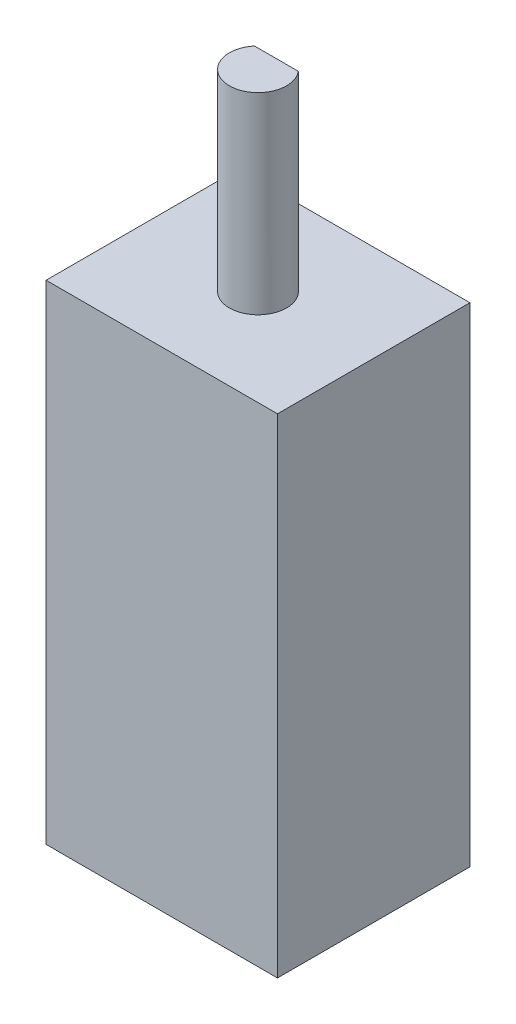
from build123d import *

# Parameters (mm, degrees)
SKETCH1_W           = 12.065
SKETCH1_H           = 25.4762
BOSS_EXTRUDE1_DEPTH = 10.033
SKETCH2_R           = 1.49225
BOSS_EXTRUDE2_DEPTH = 10.033
CUT_EXTRUDE1_DEPTH  = 8.6106


with BuildPart() as part:
    # Sketch1 → Boss-Extrude1 (new body)
    with BuildSketch(Plane.XY):
        with Locations((6.0325, 12.7381)):
            Rectangle(SKETCH1_W, SKETCH1_H)
    extrude(amount=BOSS_EXTRUDE1_DEPTH)

    # Sketch2 → Boss-Extrude2 (add)
    with BuildSketch(Plane(origin=(0, 25.4762, 0), x_dir=(1, 0, 0), z_dir=(0, 1, 0))):
        with Locations((6.0325, -5.0165)):
            Circle(SKETCH2_R)
    extrude(amount=BOSS_EXTRUDE2_DEPTH)

    # Sketch3 → Cut-Extrude1 (cut)
    with BuildSketch(Plane(origin=(0, 35.5092, 0), x_dir=(1, 0, 0), z_dir=(0, 1, 0))):
        with BuildLine():
            Line((4.890142942, -4.05638), (7.174857058, -4.05638))
            ThreePointArc((7.174857058, -4.05638), (6.0325, -3.52425), (4.890142942, -4.05638))
        make_face()
    extrude(amount=-CUT_EXTRUDE1_DEPTH, mode=Mode.SUBTRACT)


solid = part.part
